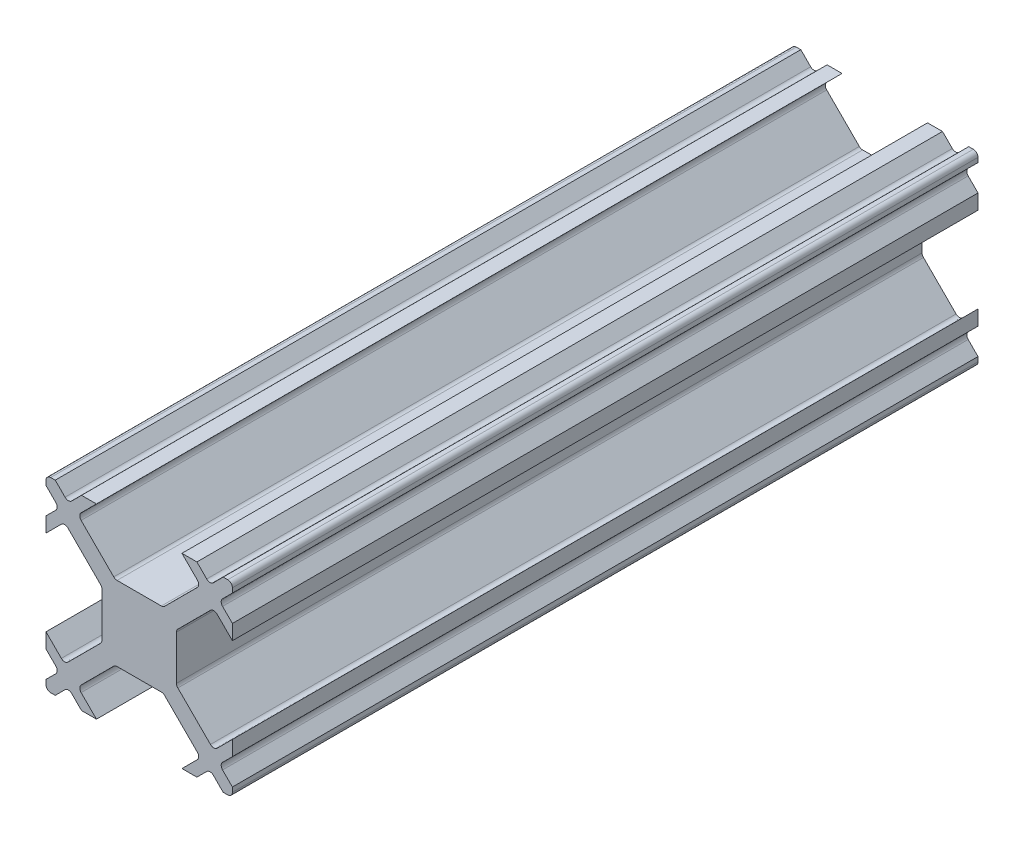
from build123d import *

# Parameters (mm, degrees)
BOSS_EXTRUDE1_DEPTH = 40


with BuildPart() as part:
    # Sketch1 → Boss-Extrude1 (new body)
    with BuildSketch(Plane.XY.offset(12.5)):
        with BuildLine():
            Line((1.189339828, 2), (-1.189339828, 2))
            ThreePointArc((-1.189339828, 2), (-1.285010686, 2.019030117), (-1.366116524, 2.073223305))
            Line((-1.366116524, 2.073223305), (-3.116116524, 3.823223305))
            ThreePointArc((-3.116116524, 3.823223305), (-3.189339828, 4), (-3.116116524, 4.176776695))
            Line((-3.116116524, 4.176776695), (-2.292893219, 5))
            Line((-2.292893219, 5), (-3.094974747, 5))
            Line((-3.094974747, 5), (-3.623223305, 4.471751442))
            ThreePointArc((-3.623223305, 4.471751442), (-3.8, 4.398528137), (-3.976776695, 4.471751442))
            Line((-3.976776695, 4.471751442), (-4.505025253, 5))
            Line((-4.505025253, 5), (-4.75, 5))
            ThreePointArc((-4.75, 5), (-4.926776695, 4.926776695), (-5, 4.75))
            Line((-5, 4.75), (-5, 4.505025253))
            Line((-5, 4.505025253), (-4.471751442, 3.976776695))
            ThreePointArc((-4.471751442, 3.976776695), (-4.398528137, 3.8), (-4.471751442, 3.623223305))
            Line((-4.471751442, 3.623223305), (-5, 3.094974747))
            Line((-5, 3.094974747), (-5, 2.292893219))
            Line((-5, 2.292893219), (-4.176776695, 3.116116524))
            ThreePointArc((-4.176776695, 3.116116524), (-4, 3.189339828), (-3.823223305, 3.116116524))
            Line((-3.823223305, 3.116116524), (-2.073223305, 1.366116524))
            ThreePointArc((-2.073223305, 1.366116524), (-2.019030117, 1.285010686), (-2, 1.189339828))
            Line((-2, 1.189339828), (-2, -1.189339828))
            ThreePointArc((-2, -1.189339828), (-2.019030117, -1.285010686), (-2.073223305, -1.366116524))
            Line((-2.073223305, -1.366116524), (-3.823223305, -3.116116524))
            ThreePointArc((-3.823223305, -3.116116524), (-4, -3.189339828), (-4.176776695, -3.116116524))
            Line((-4.176776695, -3.116116524), (-5, -2.292893219))
            Line((-5, -2.292893219), (-5, -3.094974747))
            Line((-5, -3.094974747), (-4.471751442, -3.623223305))
            ThreePointArc((-4.471751442, -3.623223305), (-4.398528137, -3.8), (-4.471751442, -3.976776695))
            Line((-4.471751442, -3.976776695), (-5, -4.505025253))
            Line((-5, -4.505025253), (-5, -4.75))
            ThreePointArc((-5, -4.75), (-4.926776695, -4.926776695), (-4.75, -5))
            Line((-4.75, -5), (-4.505025253, -5))
            Line((-4.505025253, -5), (-3.976776695, -4.471751442))
            ThreePointArc((-3.976776695, -4.471751442), (-3.8, -4.398528137), (-3.623223305, -4.471751442))
            Line((-3.623223305, -4.471751442), (-3.094974747, -5))
            Line((-3.094974747, -5), (-2.292893219, -5))
            Line((-2.292893219, -5), (-3.116116524, -4.176776695))
            ThreePointArc((-3.116116524, -4.176776695), (-3.189339828, -4), (-3.116116524, -3.823223305))
            Line((-3.116116524, -3.823223305), (-1.366116524, -2.073223305))
            ThreePointArc((-1.366116524, -2.073223305), (-1.285010686, -2.019030117), (-1.189339828, -2))
            Line((-1.189339828, -2), (1.189339828, -2))
            ThreePointArc((1.189339828, -2), (1.285010686, -2.019030117), (1.366116524, -2.073223305))
            Line((1.366116524, -2.073223305), (3.116116524, -3.823223305))
            ThreePointArc((3.116116524, -3.823223305), (3.189339828, -4), (3.116116524, -4.176776695))
            Line((3.116116524, -4.176776695), (2.292893219, -5))
            Line((2.292893219, -5), (3.094974747, -5))
            Line((3.094974747, -5), (3.623223305, -4.471751442))
            ThreePointArc((3.623223305, -4.471751442), (3.8, -4.398528137), (3.976776695, -4.471751442))
            Line((3.976776695, -4.471751442), (4.505025253, -5))
            Line((4.505025253, -5), (4.75, -5))
            ThreePointArc((4.75, -5), (4.926776695, -4.926776695), (5, -4.75))
            Line((5, -4.75), (5, -4.505025253))
            Line((5, -4.505025253), (4.471751442, -3.976776695))
            ThreePointArc((4.471751442, -3.976776695), (4.398528137, -3.8), (4.471751442, -3.623223305))
            Line((4.471751442, -3.623223305), (5, -3.094974747))
            Line((5, -3.094974747), (5, -2.292893219))
            Line((5, -2.292893219), (4.176776695, -3.116116524))
            ThreePointArc((4.176776695, -3.116116524), (4, -3.189339828), (3.823223305, -3.116116524))
            Line((3.823223305, -3.116116524), (2.073223305, -1.366116524))
            ThreePointArc((2.073223305, -1.366116524), (2.019030117, -1.285010686), (2, -1.189339828))
            Line((2, -1.189339828), (2, 1.189339828))
            ThreePointArc((2, 1.189339828), (2.019030117, 1.285010686), (2.073223305, 1.366116524))
            Line((2.073223305, 1.366116524), (3.823223305, 3.116116524))
            ThreePointArc((3.823223305, 3.116116524), (4, 3.189339828), (4.176776695, 3.116116524))
            Line((4.176776695, 3.116116524), (5, 2.292893219))
            Line((5, 2.292893219), (5, 3.094974747))
            Line((5, 3.094974747), (4.471751442, 3.623223305))
            ThreePointArc((4.471751442, 3.623223305), (4.398528137, 3.8), (4.471751442, 3.976776695))
            Line((4.471751442, 3.976776695), (5, 4.505025253))
            Line((5, 4.505025253), (5, 4.75))
            ThreePointArc((5, 4.75), (4.926776695, 4.926776695), (4.75, 5))
            Line((4.75, 5), (4.505025253, 5))
            Line((4.505025253, 5), (3.976776695, 4.471751442))
            ThreePointArc((3.976776695, 4.471751442), (3.8, 4.398528137), (3.623223305, 4.471751442))
            Line((3.623223305, 4.471751442), (3.094974747, 5))
            Line((3.094974747, 5), (2.292893219, 5))
            Line((2.292893219, 5), (3.116116524, 4.176776695))
            ThreePointArc((3.116116524, 4.176776695), (3.189339828, 4), (3.116116524, 3.823223305))
            Line((3.116116524, 3.823223305), (1.366116524, 2.073223305))
            ThreePointArc((1.366116524, 2.073223305), (1.285010686, 2.019030117), (1.189339828, 2))
        make_face()
    extrude(amount=-BOSS_EXTRUDE1_DEPTH)


solid = part.part
